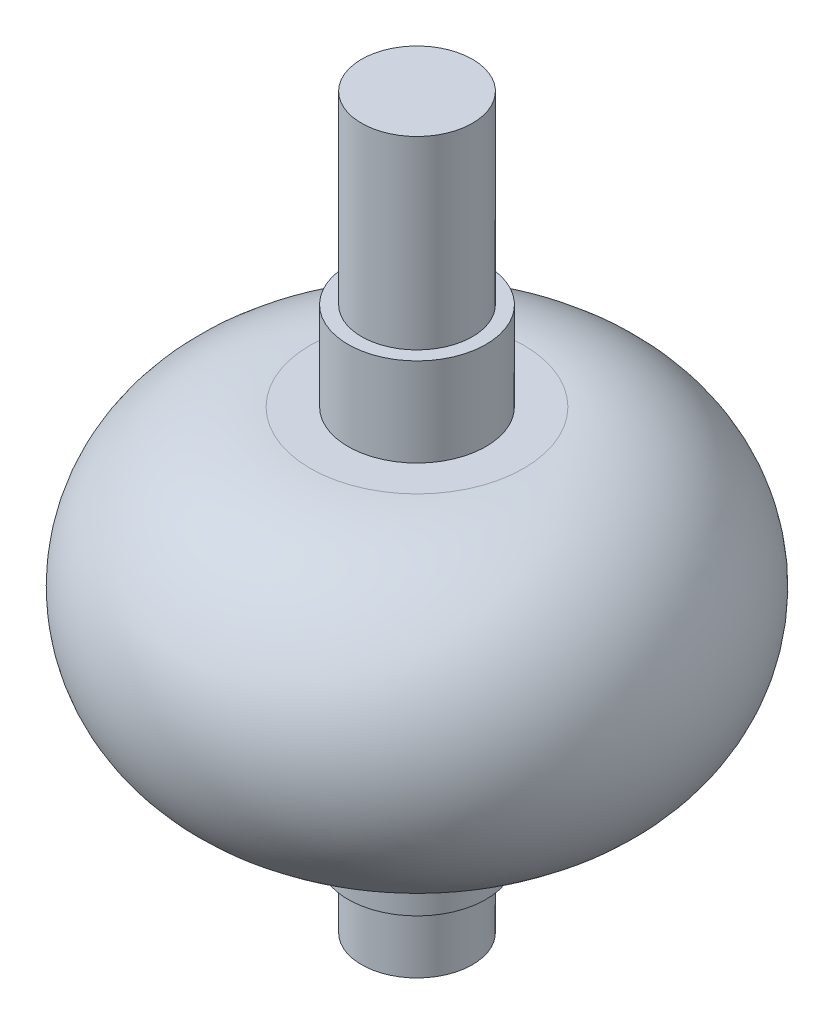
from build123d import *


with BuildPart() as part:
    # Эскиз1 → Повернуть1 (revolve)
    with BuildSketch(Plane.XY):
        with BuildLine():
            Line((0, 42.221330192), (-3, 42.221330192))
            Line((-3, 42.221330192), (-3, 32.221330192))
            Line((-3, 32.221330192), (-3.728781423, 32.221330192))
            Line((-3.728781423, 32.221330192), (-3.728781423, 27.435605162))
            Line((-3.728781423, 27.435605162), (-5.773927938, 27.435605162))
            ThreePointArc((-5.773927938, 27.435605162), (-14.185723229, 19.023809872), (-5.773927938, 10.612014581))
            Line((-5.773927938, 10.612014581), (-3.728781423, 10.612014581))
            Line((-3.728781423, 10.612014581), (-3.728781423, 6.218549743))
            Line((-3.728781423, 6.218549743), (-3, 6.218549743))
            Line((-3, 6.218549743), (-3, 2.795657314))
            Line((-3, 2.795657314), (0, 2.795657314))
            Line((0, 2.795657314), (0, 42.221330192))
        make_face()
    revolve(axis=Axis((0, 0, 0), (0, 1, 0)))


solid = part.part
